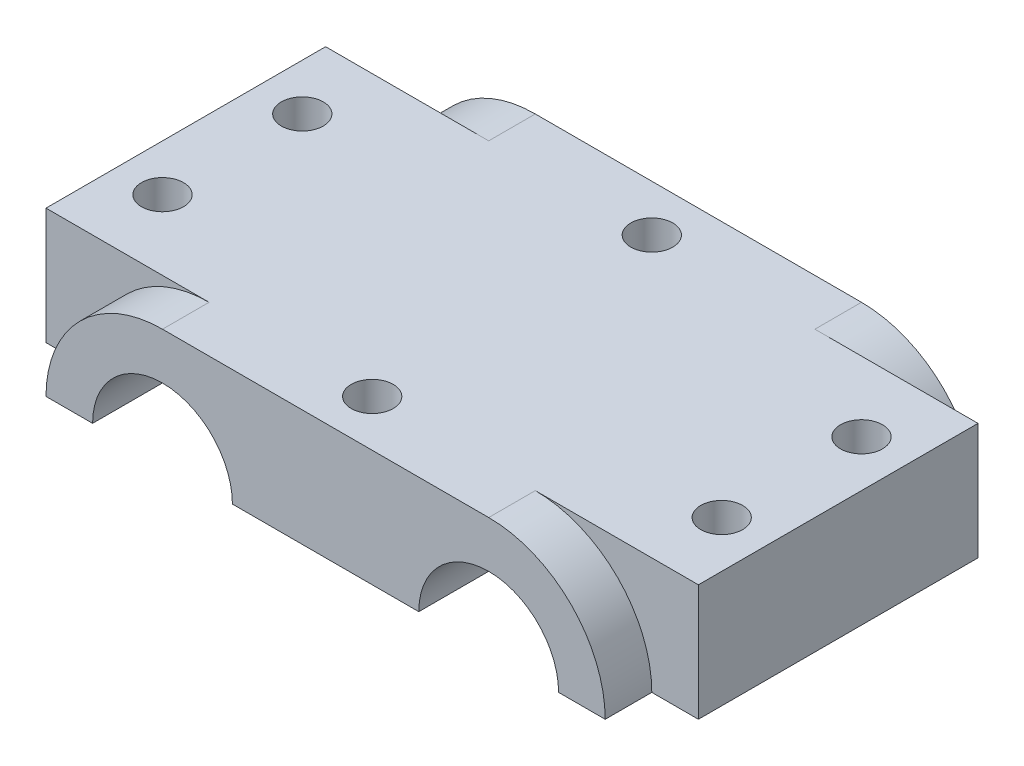
from build123d import *

# Parameters (mm, degrees)
BOSS_EXTRUDE1_DEPTH = 40
CUT_EXTRUDE1_DEPTH  = 5
CUT_EXTRUDE2_REACH  = 14.5
SKETCH3_R           = 2.25


with BuildPart() as part:
    # Sketch1 → Boss-Extrude1 (new body)
    with BuildSketch(Plane.XY):
        with BuildLine():
            Line((0, 0), (10, 0))
            ThreePointArc((10, 0), (17.5, 7.5), (25, 0))
            Line((25, 0), (45, 0))
            ThreePointArc((45, 0), (52.5, 7.5), (60, 0))
            Line((60, 0), (70, 0))
            Line((70, 0), (70, 12.5))
            Line((70, 12.5), (0, 12.5))
            Line((0, 12.5), (0, 0))
        make_face()
    extrude(amount=BOSS_EXTRUDE1_DEPTH)

    # Sketch2 → Cut-Extrude1 (cut)
    with BuildSketch(Plane.XY.offset(40)):
        with BuildLine():
            Line((0, 0), (5, 0))
            ThreePointArc((5, 0), (8.661165235, 8.838834765), (17.5, 12.5))
            Line((17.5, 12.5), (0, 12.5))
            Line((0, 12.5), (0, 0))
        make_face()
        with BuildLine():
            Line((65, 0), (70, 0))
            Line((70, 0), (70, 12.5))
            Line((70, 12.5), (52.5, 12.5))
            ThreePointArc((52.5, 12.5), (61.338834765, 8.838834765), (65, 0))
        make_face()
    cut_extrude1 = extrude(amount=-CUT_EXTRUDE1_DEPTH, mode=Mode.SUBTRACT)

    # Mirror1: Cut-Extrude1 across plane
    add(cut_extrude1.mirror(Plane(origin=(0, 0, 20), x_dir=(1, 0, 0), z_dir=(0, 0, -1))), mode=Mode.SUBTRACT)

    # Sketch3 → Cut-Extrude2 (cut, up to next)
    with BuildSketch(Plane(origin=(0, 12.5, 0), x_dir=(1, 0, 0), z_dir=(0, 1, 0)), mode=Mode.PRIVATE) as cut_extrude2_sk1:
        with Locations((35, -5)):
            Circle(SKETCH3_R)
    cut_extrude2_tool1 = extrude(cut_extrude2_sk1.sketch, amount=-CUT_EXTRUDE2_REACH, mode=Mode.PRIVATE) & part.part
    add(cut_extrude2_tool1.solids().sort_by_distance((35, 12.5, 5))[0], mode=Mode.SUBTRACT)
    # Sketch3 → Cut-Extrude2 (cut, up to next)
    with BuildSketch(Plane(origin=(0, 12.5, 0), x_dir=(1, 0, 0), z_dir=(0, 1, 0)), mode=Mode.PRIVATE) as cut_extrude2_sk2:
        with Locations((35, -35)):
            Circle(SKETCH3_R)
    cut_extrude2_tool2 = extrude(cut_extrude2_sk2.sketch, amount=-CUT_EXTRUDE2_REACH, mode=Mode.PRIVATE) & part.part
    add(cut_extrude2_tool2.solids().sort_by_distance((35, 12.5, 35))[0], mode=Mode.SUBTRACT)
    # Sketch3 → Cut-Extrude2 (cut, up to next)
    with BuildSketch(Plane(origin=(0, 12.5, 0), x_dir=(1, 0, 0), z_dir=(0, 1, 0)), mode=Mode.PRIVATE) as cut_extrude2_sk3:
        with Locations((5, -12.5)):
            Circle(SKETCH3_R)
    cut_extrude2_tool3 = extrude(cut_extrude2_sk3.sketch, amount=-CUT_EXTRUDE2_REACH, mode=Mode.PRIVATE) & part.part
    add(cut_extrude2_tool3.solids().sort_by_distance((5, 12.5, 12.5))[0], mode=Mode.SUBTRACT)
    # Sketch3 → Cut-Extrude2 (cut, up to next)
    with BuildSketch(Plane(origin=(0, 12.5, 0), x_dir=(1, 0, 0), z_dir=(0, 1, 0)), mode=Mode.PRIVATE) as cut_extrude2_sk4:
        with Locations((5, -27.5)):
            Circle(SKETCH3_R)
    cut_extrude2_tool4 = extrude(cut_extrude2_sk4.sketch, amount=-CUT_EXTRUDE2_REACH, mode=Mode.PRIVATE) & part.part
    add(cut_extrude2_tool4.solids().sort_by_distance((5, 12.5, 27.5))[0], mode=Mode.SUBTRACT)
    # Sketch3 → Cut-Extrude2 (cut, up to next)
    with BuildSketch(Plane(origin=(0, 12.5, 0), x_dir=(1, 0, 0), z_dir=(0, 1, 0)), mode=Mode.PRIVATE) as cut_extrude2_sk5:
        with Locations((65, -12.5)):
            Circle(SKETCH3_R)
    cut_extrude2_tool5 = extrude(cut_extrude2_sk5.sketch, amount=-CUT_EXTRUDE2_REACH, mode=Mode.PRIVATE) & part.part
    add(cut_extrude2_tool5.solids().sort_by_distance((65, 12.5, 12.5))[0], mode=Mode.SUBTRACT)
    # Sketch3 → Cut-Extrude2 (cut, up to next)
    with BuildSketch(Plane(origin=(0, 12.5, 0), x_dir=(1, 0, 0), z_dir=(0, 1, 0)), mode=Mode.PRIVATE) as cut_extrude2_sk6:
        with Locations((65, -27.5)):
            Circle(SKETCH3_R)
    cut_extrude2_tool6 = extrude(cut_extrude2_sk6.sketch, amount=-CUT_EXTRUDE2_REACH, mode=Mode.PRIVATE) & part.part
    add(cut_extrude2_tool6.solids().sort_by_distance((65, 12.5, 27.5))[0], mode=Mode.SUBTRACT)


solid = part.part
